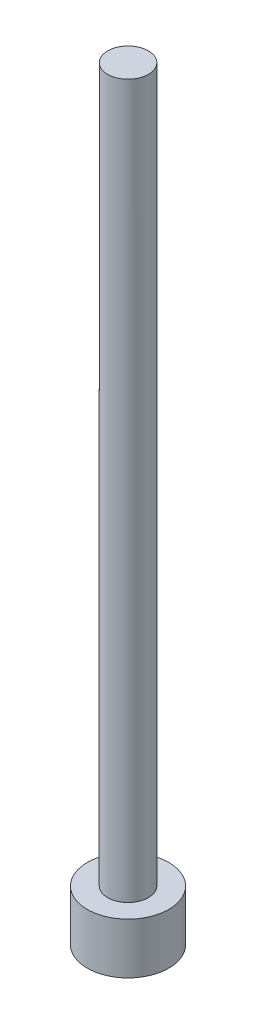
from build123d import *

# Parameters (mm, degrees)
SKETCH1_R           = 4
BOSS_EXTRUDE1_DEPTH = 150
SKETCH2_R           = 8
BOSS_EXTRUDE2_DEPTH = 10


with BuildPart() as part:
    # Sketch1 → Boss-Extrude1 (new body)
    with BuildSketch(Plane(origin=(0, 0, 0), x_dir=(1, 0, 0), z_dir=(0, 1, 0))):
        Circle(SKETCH1_R)
    extrude(amount=BOSS_EXTRUDE1_DEPTH)

    # Sketch2 → Boss-Extrude2 (add)
    with BuildSketch(Plane.XZ):
        Circle(SKETCH2_R)
    extrude(amount=-BOSS_EXTRUDE2_DEPTH)


solid = part.part
